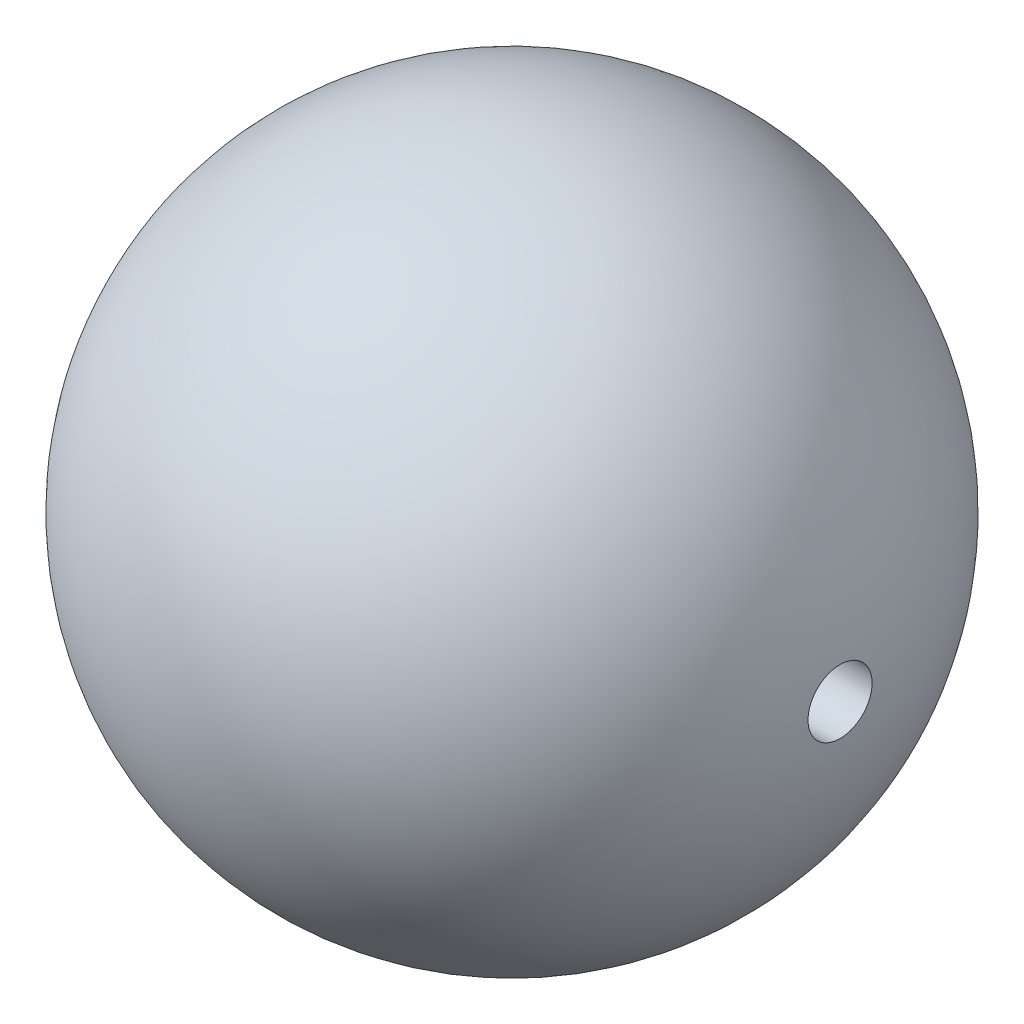
from build123d import *


with BuildPart() as part:
    # Croquis1 → Revolución2 (revolve)
    with BuildSketch(Plane(origin=(0, 0, 0), x_dir=(1, 0, 0), z_dir=(0, 1, 0))):
        with BuildLine():
            Line((-6.78992812, 0), (-18, 0))
            ThreePointArc((-18, 0), (-0.876038129, 17.978669506), (17.914728577, 1.75))
            Line((17.914728577, 1.75), (-6.78992812, 1.75))
            Line((-6.78992812, 1.75), (-6.78992812, 0))
        make_face()
    revolve(axis=Axis((-6.78992812, 0, 0), (-1, 0, 0)))


solid = part.part
